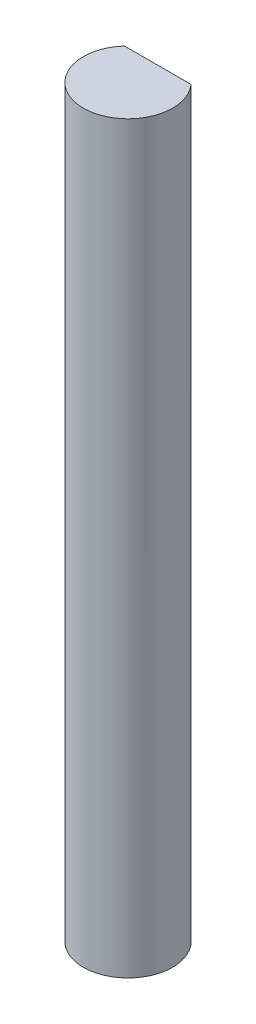
from build123d import *

# Parameters (mm, degrees)
SKETCH1_R           = 3
BOSS_EXTRUDE1_DEPTH = 50
CUT_EXTRUDE1_DEPTH  = 12


with BuildPart() as part:
    # Sketch1 → Boss-Extrude1 (new body)
    with BuildSketch(Plane(origin=(0, 0, 0), x_dir=(1, 0, 0), z_dir=(0, 1, 0))):
        Circle(SKETCH1_R)
    extrude(amount=BOSS_EXTRUDE1_DEPTH)

    # Sketch2 → Cut-Extrude1 (cut)
    with BuildSketch(Plane(origin=(0, 50, 0), x_dir=(1, 0, 0), z_dir=(0, 1, 0))):
        with BuildLine():
            Line((-2.236067977, 2), (2.236067977, 2))
            ThreePointArc((2.236067977, 2), (0, 3), (-2.236067977, 2))
        make_face()
    extrude(amount=-CUT_EXTRUDE1_DEPTH, mode=Mode.SUBTRACT)


solid = part.part
